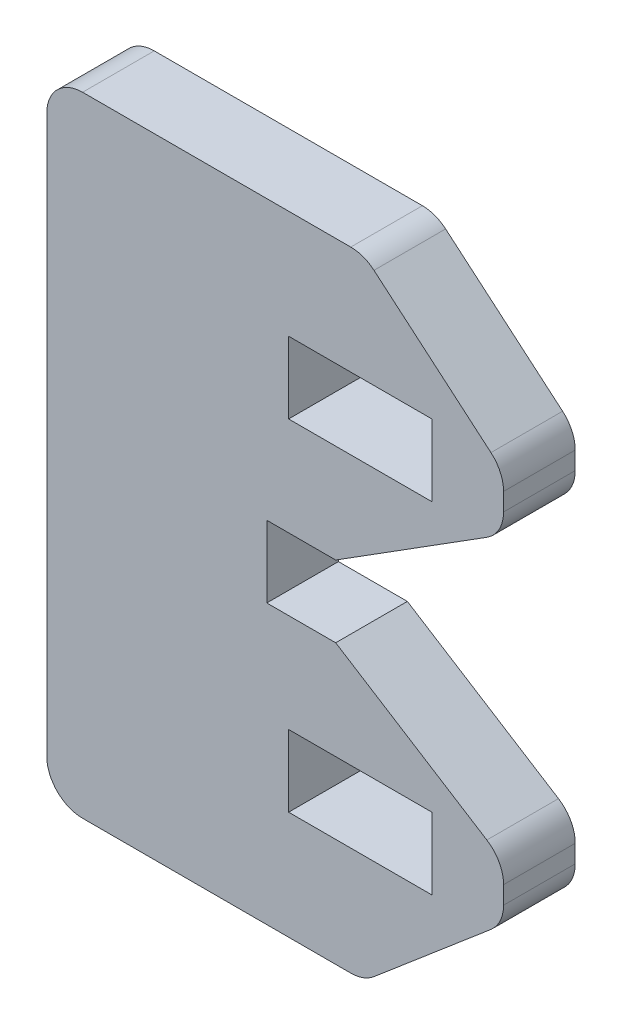
from build123d import *

# Parameters (mm, degrees)
SKETCH1_W           = 3.048
SKETCH1_H           = 1.524
BOSS_EXTRUDE1_DEPTH = 1.524


with BuildPart() as part:
    # Sketch1 → Boss-Extrude1 (new body)
    with BuildSketch(Plane.XY):
        with BuildLine():
            Line((71.633966028, -1.524), (73.100370076, -1.524))
            Line((73.100370076, -1.524), (76.314988323, -3.549713839))
            ThreePointArc((76.314988323, -3.549713839), (76.575900985, -3.82622986), (76.670741226, -4.194389956))
            Line((76.670741226, -4.194389956), (76.670741226, -4.572894715))
            ThreePointArc((76.670741226, -4.572894715), (76.600333337, -4.892807754), (76.402120879, -5.153601627))
            Line((76.402120879, -5.153601627), (73.914078319, -7.267489978))
            ThreePointArc((73.914078319, -7.267489978), (73.683515458, -7.402025217), (73.420698665, -7.448783066))
            Line((73.420698665, -7.448783066), (67.716985472, -7.448783066))
            ThreePointArc((67.716985472, -7.448783066), (67.178170104, -7.225598434), (66.954985472, -6.686783066))
            Line((66.954985472, -6.686783066), (66.954985472, 5.162783066))
            ThreePointArc((66.954985472, 5.162783066), (67.178170104, 5.701598434), (67.716985472, 5.924783066))
            Line((67.716985472, 5.924783066), (73.420698665, 5.924783066))
            ThreePointArc((73.420698665, 5.924783066), (73.683515458, 5.878025217), (73.914078319, 5.743489978))
            Line((73.914078319, 5.743489978), (76.402120879, 3.629601627))
            ThreePointArc((76.402120879, 3.629601627), (76.600333337, 3.368807754), (76.670741226, 3.048894715))
            Line((76.670741226, 3.048894715), (76.670741226, 2.670389956))
            ThreePointArc((76.670741226, 2.670389956), (76.575900985, 2.30222986), (76.314988323, 2.025713839))
            Line((76.314988323, 2.025713839), (73.100370076, 0))
            Line((73.100370076, 0), (71.633966028, 0))
            Line((71.633966028, 0), (71.633966028, -1.524))
        make_face()
        with Locations((73.622741226, 2.859642336)):
            Rectangle(SKETCH1_W, SKETCH1_H, mode=Mode.SUBTRACT)
        with Locations((73.622741226, -4.383642336)):
            Rectangle(SKETCH1_W, SKETCH1_H, mode=Mode.SUBTRACT)
    extrude(amount=BOSS_EXTRUDE1_DEPTH)


solid = part.part
